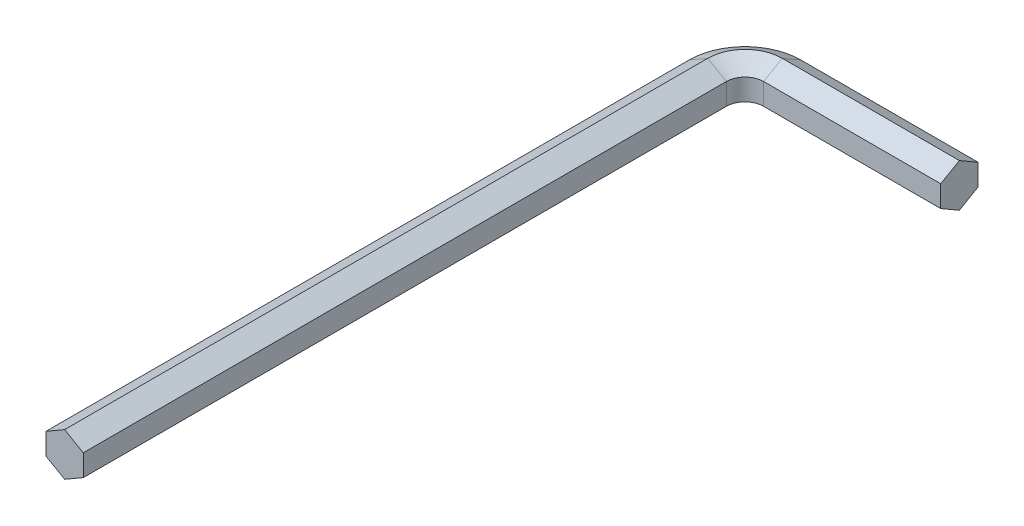
from build123d import *


with BuildPart() as part:
    # Sweep2: sweep along a path in Sketch1
    with BuildLine(Plane(origin=(0, 0, 0), x_dir=(1, 0, 0), z_dir=(0, 1, 0))) as sweep2_path:
        Line((0, 0), (0, 69))
        ThreePointArc((0, 69), (1.757359313, 73.242640687), (6, 75))
        Line((6, 75), (25, 75))
    # Sketch3 → Sweep2 (sweep)
    with BuildSketch(Plane(origin=(25, 0, 0), x_dir=(0, 0, -1), z_dir=(1, 0, 0))):
        Polygon((75, -1.154700538), (75, 1.154700538), (73, 2.309401077), (71, 1.154700538), (71, -1.154700538), (73, -2.309401077), align=None)
    sweep(path=sweep2_path.line)


solid = part.part
